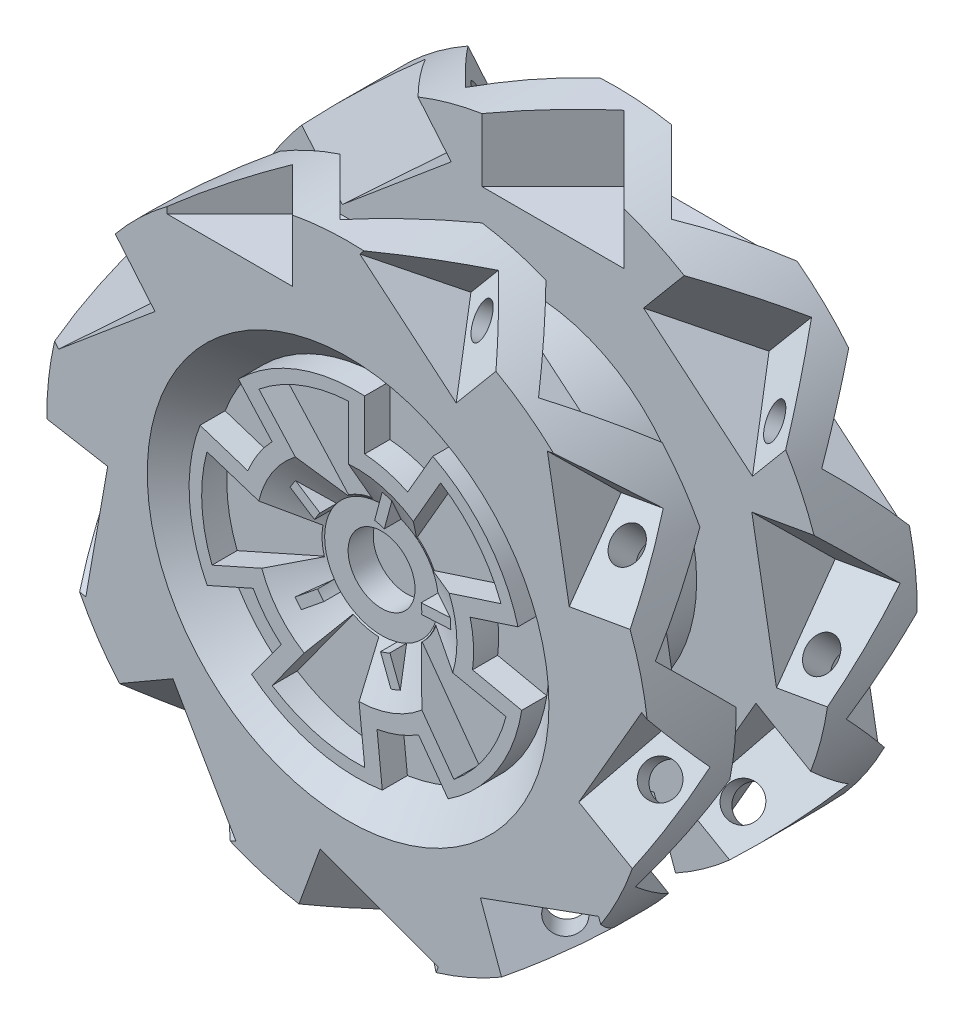
from build123d import *

# Parameters (mm, degrees)
SKETCH1_R               = 228.6
BOSS_EXTRUDE1_DEPTH     = 101.6
CUT_EXTRUDE1_DEPTH      = 50.8
CIRPATTERN1_COUNT       = 9
CUT_EXTRUDE2_START      = -158.305837596
SKETCH3_R               = 12.7
CUT_EXTRUDE2_DEPTH      = 468.973318296
CIRPATTERN2_COUNT       = 9
SKETCH4_W               = 71.762146906
SKETCH4_H               = 520.956421286
CUT_EXTRUDE3_DEPTH      = 229.6
CUT_EXTRUDE3_DEPTH_BACK = 229.6
SKETCH5_R               = 127
BOSS_EXTRUDE2_DEPTH     = 101.6
SKETCH8_R               = 152.4
CUT_EXTRUDE5_DEPTH      = 25.4
CUT_EXTRUDE5_TAPER      = 45
SKETCH9_R               = 31.75
BOSS_EXTRUDE4_DEPTH     = 19.05
SKETCH10_R              = 76.2
CUT_EXTRUDE6_DEPTH      = 19.05
CUT_EXTRUDE6_TAPER      = 60
SKETCH11_R              = 25.4
CUT_EXTRUDE7_DEPTH      = 19.05
BOSS_EXTRUDE5_DEPTH     = 12.7
SKETCH14_R              = 101.6
SKETCH14_R_2            = 50.8
SKETCH14_R_3            = 31.75
CUT_EXTRUDE8_DEPTH      = 101.6
FILLET1_R               = 25.4


with BuildPart() as part:
    # Sketch1 → Boss-Extrude1 (new body, symmetric)
    with BuildSketch(Plane.XY):
        Circle(SKETCH1_R)
    extrude(amount=BOSS_EXTRUDE1_DEPTH, both=True)

    # Sketch2 → Cut-Extrude1 (cut)
    with BuildSketch(Plane(origin=(0, 228.6, 0), x_dir=(1, 0, 0), z_dir=(0, 1, 0))):
        Polygon((-17.974073453, -89.816122421), (-89.816122421, -17.974073453), (17.946951031, 89.789), (89.789, 17.946951031), align=None)
        Polygon((89.789, 53.867975516), (35.907463274, 107.749512242), (89.789, 161.631048969), (143.670536726, 107.749512242), align=None)
        Polygon((-89.816122421, -161.65817139), (-35.934585695, -107.776634664), (-89.816122421, -53.895097937), (-143.697659148, -107.776634664), align=None)
    cut_extrude1 = extrude(amount=-CUT_EXTRUDE1_DEPTH, mode=Mode.SUBTRACT)

    # CirPattern1: Cut-Extrude1 ×9 about axis
    cirpattern1_axis = Axis((0, 0, 0), (0, 0, 1))
    for i in range(1, CIRPATTERN1_COUNT):
        add(cut_extrude1.rotate(cirpattern1_axis, i * 360 / CIRPATTERN1_COUNT), mode=Mode.SUBTRACT)

    # Sketch3 → Cut-Extrude2 (cut)
    with BuildSketch(Plane(origin=(53.867975516, 0, -53.867975516), x_dir=(0.707106781, 0, 0.707106781), z_dir=(-0.707106781, 0, 0.707106781)).offset(CUT_EXTRUDE2_START)):
        with Locations((0, 197.528198582)):
            Circle(SKETCH3_R)
    cut_extrude2 = extrude(amount=CUT_EXTRUDE2_DEPTH, mode=Mode.SUBTRACT)

    # CirPattern2: Cut-Extrude2 ×9 about axis
    cirpattern2_axis = Axis((0, 0, 101.6), (0, 0, -1))
    for i in range(1, CIRPATTERN2_COUNT):
        add(cut_extrude2.rotate(cirpattern2_axis, i * 360 / CIRPATTERN2_COUNT), mode=Mode.SUBTRACT)

    # Sketch4 → Cut-Extrude3 (cut, two sides)
    with BuildSketch(Plane(origin=(0, 0, 0), x_dir=(0, 0, -1), z_dir=(1, 0, 0))) as cut_extrude3_sk:
        Rectangle(SKETCH4_W, SKETCH4_H)
    extrude(amount=CUT_EXTRUDE3_DEPTH, mode=Mode.SUBTRACT)
    extrude(cut_extrude3_sk.sketch, amount=-CUT_EXTRUDE3_DEPTH_BACK, mode=Mode.SUBTRACT)

    # Sketch5 → Boss-Extrude2 (add, symmetric)
    with BuildSketch(Plane.XY):
        Circle(SKETCH5_R)
    extrude(amount=BOSS_EXTRUDE2_DEPTH, both=True)

    # Sketch8 → Cut-Extrude5 (cut)
    with BuildSketch(Plane.XY.offset(101.6)):
        Circle(SKETCH8_R)
    extrude(amount=-CUT_EXTRUDE5_DEPTH, taper=CUT_EXTRUDE5_TAPER, mode=Mode.SUBTRACT)

    # Sketch9 → Boss-Extrude4 (add, symmetric)
    with BuildSketch(Plane.XY.offset(76.2)):
        with BuildLine():
            Line((38.822788399, 79.975002975), (57.907073989, 113.029955242))
            ThreePointArc((57.907073989, 113.029955242), (98.651357219, 79.98068341), (122.56117085, 33.283019692))
            Line((122.56117085, 33.283019692), (86.263678111, 21.489249377))
            ThreePointArc((86.263678111, 21.489249377), (88.774291341, 4.7260128), (88.057649105, -12.209030843))
            Line((88.057649105, -12.209030843), (125.392145427, -20.144723013))
            ThreePointArc((125.392145427, -20.144723013), (106.551096034, -69.107625729), (69.527517403, -106.277581473))
            Line((69.527517403, -106.277581473), (47.094433184, -75.401089933))
            ThreePointArc((47.094433184, -75.401089933), (31.927469958, -82.968949988), (15.599831717, -87.520599006))
            Line((15.599831717, -87.520599006), (19.589533807, -125.480078758))
            ThreePointArc((19.589533807, -125.480078758), (-32.799158332, -122.691544993), (-79.590801942, -98.966177284))
            Line((-79.590801942, -98.966177284), (-57.157717722, -68.089685744))
            ThreePointArc((-57.157717722, -68.089685744), (-69.042029732, -56.003643904), (-78.416422885, -41.881674058))
            Line((-78.416422885, -41.881674058), (-113.28514771, -57.40623057))
            ThreePointArc((-113.28514771, -57.40623057), (-126.822090685, -6.719919208), (-118.717338195, 45.113120175))
            Line((-118.717338195, 45.113120175), (-82.419845456, 33.31934986))
            ThreePointArc((-82.419845456, 33.31934986), (-74.597790984, 48.356794562), (-64.063846336, 61.636300933))
            Line((-64.063846336, 61.636300933), (-89.603605513, 90.0010771))
            ThreePointArc((-89.603605513, 90.0010771), (-45.581204236, 118.53840652), (6.219451883, 126.847618891))
            Line((6.219451883, 126.847618891), (6.219451883, 88.682176441))
            ThreePointArc((6.219451883, 88.682176441), (22.938059418, 85.88978653), (38.822788399, 79.975002975))
        make_face()
        Circle(SKETCH9_R, mode=Mode.SUBTRACT)
        with BuildLine():
            Line((-6.141898908, 44.023625223), (-6.141898908, 117.314332896))
            ThreePointArc((-6.141898908, 117.314332896), (-42.167756231, 109.646048536), (-74.048254053, 91.198857979))
            Line((-74.048254053, 91.198857979), (-25.015639221, 36.742622312))
            ThreePointArc((-25.015639221, 36.742622312), (-15.998477941, 41.471088768), (-6.141898908, 44.023625223))
        make_face(mode=Mode.SUBTRACT)
        with BuildLine():
            Line((27.214052731, 35.145381403), (63.853099253, 98.606071521))
            ThreePointArc((63.853099253, 98.606071521), (91.249035656, 73.986411704), (109.674609615, 42.093415527))
            Line((109.674609615, 42.093415527), (39.971004499, 19.445341327))
            ThreePointArc((39.971004499, 19.445341327), (34.497547643, 28.030727901), (27.214052731, 35.145381403))
        make_face(mode=Mode.SUBTRACT)
        with BuildLine():
            Line((41.834848781, -15.021582057), (113.511639679, -30.256954282))
            ThreePointArc((113.511639679, -30.256954282), (98.562761707, -63.919931397), (73.924535353, -91.299171397))
            Line((73.924535353, -91.299171397), (30.845338253, -32.005743361))
            ThreePointArc((30.845338253, -32.005743361), (37.319134912, -24.147146196), (41.834848781, -15.021582057))
        make_face(mode=Mode.SUBTRACT)
        with BuildLine():
            Line((-1.35869427, -44.429229679), (6.300952187, -117.305897663))
            ThreePointArc((6.300952187, -117.305897663), (-30.333898896, -113.491101866), (-63.986734164, -98.519406596))
            Line((-63.986734164, -98.519406596), (-20.907537064, -39.225978559))
            ThreePointArc((-20.907537064, -39.225978559), (-11.433053836, -42.954484981), (-1.35869427, -44.429229679))
        make_face(mode=Mode.SUBTRACT)
        with BuildLine():
            Line((-42.67456802, -12.437191979), (-109.617437066, -42.242077555))
            ThreePointArc((-109.617437066, -42.242077555), (-117.310142236, -6.221426977), (-113.470511896, 30.41082957))
            Line((-113.470511896, 30.41082957), (-43.76690678, 7.762755369))
            ThreePointArc((-43.76690678, 7.762755369), (-44.385150778, -2.400185492), (-42.67456802, -12.437191979))
        make_face(mode=Mode.SUBTRACT)
    extrude(amount=BOSS_EXTRUDE4_DEPTH, both=True)

    # Sketch10 → Cut-Extrude6 (cut)
    with BuildSketch(Plane.XY.offset(95.25)):
        Circle(SKETCH10_R)
    extrude(amount=-CUT_EXTRUDE6_DEPTH, taper=CUT_EXTRUDE6_TAPER, mode=Mode.SUBTRACT)

    # Sketch11 → Cut-Extrude7 (cut)
    with BuildSketch(Plane.XY.offset(76.2)):
        Circle(SKETCH11_R)
    extrude(amount=-CUT_EXTRUDE7_DEPTH, mode=Mode.SUBTRACT)

    # Sketch13 → Boss-Extrude5 (add, symmetric)
    with BuildSketch(Plane.XY.offset(76.2)):
        with BuildLine():
            Line((76.199674644, 0.222674895), (43.177436241, -1.527073693))
            ThreePointArc((43.177436241, -1.527073693), (43.143908723, 2.286065301), (42.774286451, 6.081395651))
            Line((42.774286451, 6.081395651), (75.796524854, 7.831144239))
            ThreePointArc((75.796524854, 7.831144239), (76.093254411, 4.031951525), (76.199674644, 0.222674895))
        make_face()
        with BuildLine():
            Line((15.974553536, 74.50673553), (7.434230474, 42.560018465))
            ThreePointArc((7.434230474, 42.560018465), (11.158023698, 41.738728558), (14.794894959, 40.592290372))
            Line((14.794894959, 40.592290372), (23.335218021, 72.539007437))
            ThreePointArc((23.335218021, 72.539007437), (19.679494999, 73.614926996), (15.974553536, 74.50673553))
        make_face()
        with BuildLine():
            Line((23.758770841, -72.401386783), (11.890228185, -41.536073817))
            ThreePointArc((11.890228185, -41.536073817), (15.506378301, -40.325862501), (19.001732397, -38.801509253))
            Line((19.001732397, -38.801509253), (30.870275053, -69.666822219))
            ThreePointArc((30.870275053, -69.666822219), (27.348722542, -71.123043912), (23.758770841, -72.401386783))
        make_face()
        with BuildLine():
            Line((-61.515946734, -44.96919276), (-35.828871089, -24.143631685))
            ThreePointArc((-35.828871089, -24.143631685), (-33.560439891, -27.208818953), (-31.030569984, -30.062047184))
            Line((-31.030569984, -30.062047184), (-56.717645629, -50.887608259))
            ThreePointArc((-56.717645629, -50.887608259), (-59.190814332, -47.988410046), (-61.515946734, -44.96919276))
        make_face()
        with BuildLine():
            Line((-61.777716772, 44.608897211), (-34.033688297, 26.614488824))
            ThreePointArc((-34.033688297, 26.614488824), (-36.24787083, 23.509887595), (-38.179679338, 20.222142322))
            Line((-38.179679338, 20.222142322), (-65.923707814, 38.216550709))
            ThreePointArc((-65.923707814, 38.216550709), (-63.93065762, 41.464575438), (-61.777716772, 44.608897211))
        make_face()
    extrude(amount=BOSS_EXTRUDE5_DEPTH, both=True)

    # Sketch14 → Cut-Extrude8 (cut)
    with BuildSketch(Plane(origin=(0, 0, -101.6), x_dir=(-1, 0, 0), z_dir=(0, 0, -1))):
        Circle(SKETCH14_R)
        Circle(SKETCH14_R_2, mode=Mode.SUBTRACT)
        Circle(SKETCH14_R_3)
    extrude(amount=-CUT_EXTRUDE8_DEPTH, mode=Mode.SUBTRACT)

    # Fillet1
    fillet1_edges = [part.edges().sort_by_distance(p)[0] for p in [
        (50.8, 0, 0),
    ]]
    fillet(fillet1_edges, radius=FILLET1_R)


solid = part.part
